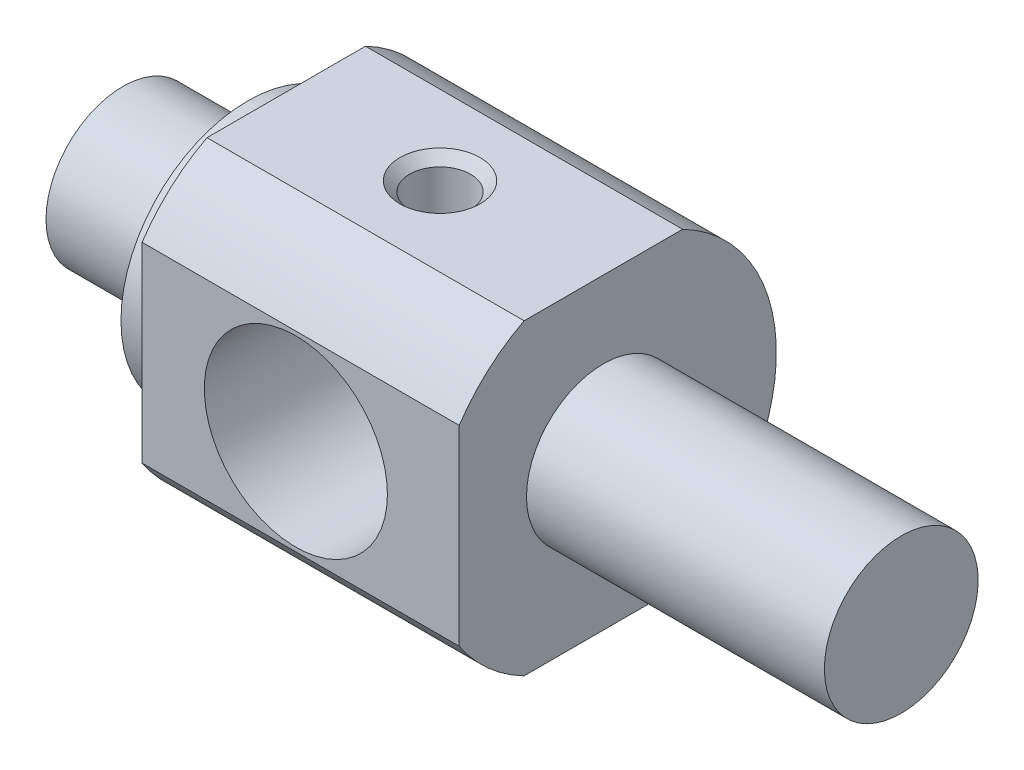
from build123d import *

# Parameters (mm, degrees)
SKETCH2_W                  = 20
SKETCH2_H                  = 12.7
CUT_EXTRUDE1_DEPTH         = 1.5
F_8_32_TAPPED_HOLE1_D      = 3.4544
F_8_32_TAPPED_HOLE1_DEPTH  = 10.71
F_8_32_TAPPED_HOLE1_TIP    = 1.037806461
SKETCH7_OUTSIDE_W          = 27.958
SKETCH7_OUTSIDE_H          = 29.458
SKETCH7_OUTSIDE_R          = 6.6
CUT_EXTRUDE2_DEPTH         = 2
F_3_8_0_3750_DOWEL_HOLE2_D = 9.525
CUT_EXTRUDE4_START         = 9
SKETCH11_W                 = 18
SKETCH11_H                 = 20
CUT_EXTRUDE4_DEPTH         = 1
F_1_8_0_1250_DOWEL_HOLE1_D = 3.175
CHAMFER1_SIZE              = 0.5


with BuildPart() as part:
    # Sketch1 → Revolve1 (revolve)
    with BuildSketch(Plane(origin=(0, 0, 0), x_dir=(1, 0, 0), z_dir=(0, 1, 0))):
        Polygon((-16.5, 0), (24, 0), (24, 4), (8.5, 4), (8.5, 9), (-10, 9), (-10, 4), (-16.5, 4), align=None)
    revolve(axis=Axis((-16.5, 0, 0), (1, 0, 0)))

    # Sketch2 → Cut-Extrude1 (cut)
    with BuildSketch(Plane.XY.offset(9)):
        Rectangle(SKETCH2_W, SKETCH2_H)
    extrude(amount=-CUT_EXTRUDE1_DEPTH, mode=Mode.SUBTRACT)

    # #8-32 Tapped Hole1
    with Locations(Plane.ZY.offset(16.5)):
        with Locations((0, 0)):
            Hole(F_8_32_TAPPED_HOLE1_D / 2, depth=F_8_32_TAPPED_HOLE1_DEPTH)
            with Locations((0, 0, -(F_8_32_TAPPED_HOLE1_DEPTH + F_8_32_TAPPED_HOLE1_TIP / 2))):  # 118° drill point
                Cone(0, F_8_32_TAPPED_HOLE1_D / 2, F_8_32_TAPPED_HOLE1_TIP, mode=Mode.SUBTRACT)

    # Sketch7 outside → Cut-Extrude2 (cut)
    with BuildSketch(Plane.ZY.offset(10)):
        with Locations((-0.75, 0)):
            Rectangle(SKETCH7_OUTSIDE_W, SKETCH7_OUTSIDE_H)
        Circle(SKETCH7_OUTSIDE_R, mode=Mode.SUBTRACT)
    extrude(amount=-CUT_EXTRUDE2_DEPTH, mode=Mode.SUBTRACT)

    # 3/8 (0.3750) Dowel Hole2 (through all)
    with Locations(Plane.XY.offset(7.5)):
        with Locations((0, 0)):
            Hole(F_3_8_0_3750_DOWEL_HOLE2_D / 2)

    # Sketch11 → Cut-Extrude4 (cut)
    with BuildSketch(Plane(origin=(0, 0, 0), x_dir=(1, 0, 0), z_dir=(0, 1, 0)).offset(CUT_EXTRUDE4_START)):
        Rectangle(SKETCH11_W, SKETCH11_H)
    cut_extrude4 = extrude(amount=-CUT_EXTRUDE4_DEPTH, mode=Mode.SUBTRACT)

    # 1/8 (0.1250) Dowel Hole1 (through all)
    with Locations(Plane(origin=(0, 8, 0), x_dir=(1, 0, 0), z_dir=(0, 1, 0))):
        with Locations((0, 0)):
            Hole(F_1_8_0_1250_DOWEL_HOLE1_D / 2)

    # Mirror1: Cut-Extrude4 across plane
    add(cut_extrude4.mirror(Plane.ZX), mode=Mode.SUBTRACT)

    # Chamfer1
    chamfer1_edges = [part.edges().sort_by_distance(p)[0] for p in [
        (1.5875, 8, 0),
    ]]
    chamfer(chamfer1_edges, length=CHAMFER1_SIZE)


solid = part.part
